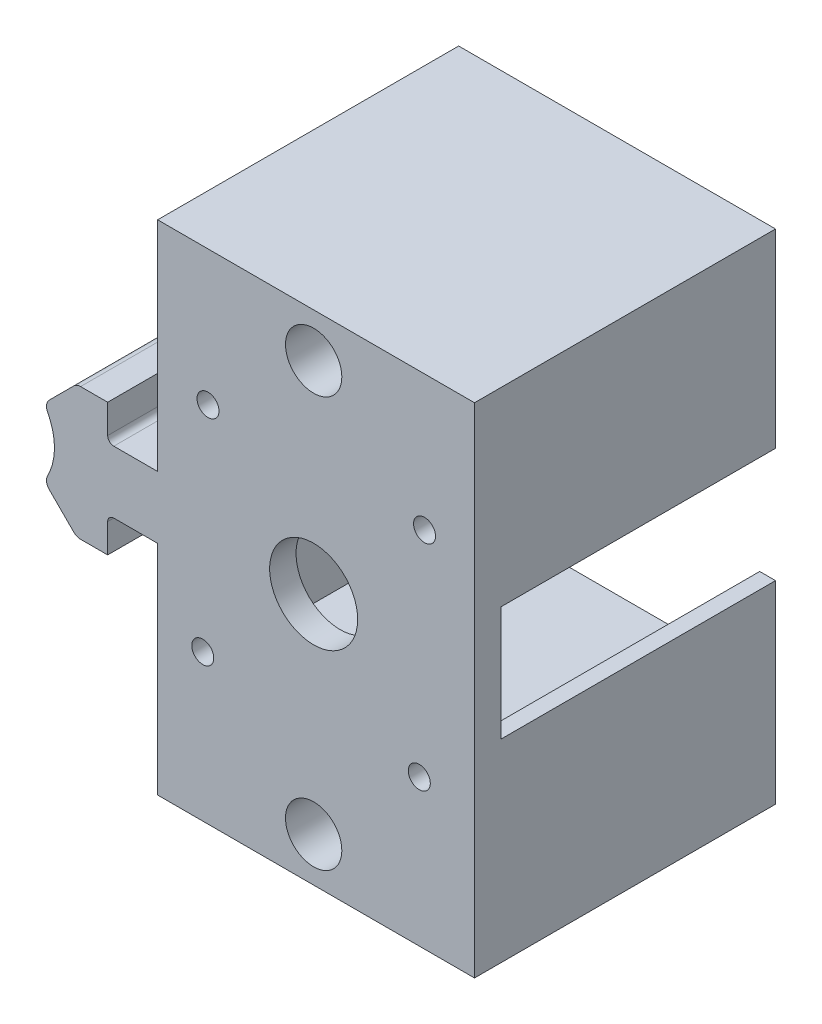
from build123d import *

# Parameters (mm, degrees)
BOSS_EXTRUDE1_DEPTH = 43.434
SKETCH3_W           = 3.81
SKETCH3_H           = 46.482
BOSS_EXTRUDE2_DEPTH = 43.688
BOSS_EXTRUDE5_DEPTH = 39.624
SKETCH9_R           = 6.35
CUT_EXTRUDE1_DEPTH  = 44.434
SKETCH10_R          = 1.5875
CUT_EXTRUDE2_DEPTH  = 4.81
SKETCH12_W          = 45.72
SKETCH12_H          = 43.434
BOSS_EXTRUDE6_DEPTH = 12.7
SKETCH13_W          = 45.72
SKETCH13_H          = 43.434
BOSS_EXTRUDE7_DEPTH = 12.7
SKETCH14_R          = 4.064
CUT_EXTRUDE3_DEPTH  = 6.35


with BuildPart() as part:
    # Sketch2 → Boss-Extrude1 (new body)
    with BuildSketch(Plane.XY.offset(816.492372385)):
        with BuildLine():
            Line((35.750095932, 34.097582937), (35.750095932, 33.285263123))
            ThreePointArc((35.750095932, 33.285263123), (35.457981836, 31.445408446), (34.772439624, 29.71323416))
            ThreePointArc((34.772439624, 29.71323416), (34.62798184, 28.864383796), (35.01595222, 28.095687512))
            Line((35.01595222, 28.095687512), (38.55890274, 24.552736992))
            ThreePointArc((38.55890274, 24.552736992), (39.005633691, 24.254240914), (39.532588778, 24.14942303))
            Line((39.532588778, 24.14942303), (43.443796213, 24.14942303))
            Line((43.443796213, 24.14942303), (43.443796213, 28.31442303))
            ThreePointArc((43.443796213, 28.31442303), (43.703006711, 28.940212531), (44.328796213, 29.19942303))
            Line((44.328796213, 29.19942303), (48.113296213, 29.19942303))
            Line((48.113296213, 29.19942303), (50.653296213, 29.19942303))
            Line((50.653296213, 29.19942303), (50.653296213, 10.45042303))
            Line((50.653296213, 10.45042303), (52.685296213, 10.45042303))
            Line((52.685296213, 10.45042303), (52.685296213, 56.93242303))
            Line((52.685296213, 56.93242303), (50.653296213, 56.93242303))
            Line((50.653296213, 56.93242303), (50.653296213, 38.18342303))
            Line((50.653296213, 38.18342303), (48.113296213, 38.18342303))
            Line((48.113296213, 38.18342303), (44.328796213, 38.18342303))
            ThreePointArc((44.328796213, 38.18342303), (43.703006711, 38.442633529), (43.443796213, 39.06842303))
            Line((43.443796213, 39.06842303), (43.443796213, 43.23342303))
            Line((43.443796213, 43.23342303), (39.532588778, 43.23342303))
            ThreePointArc((39.532588778, 43.23342303), (39.005633691, 43.128605146), (38.55890274, 42.830109068))
            Line((38.55890274, 42.830109068), (35.01595222, 39.287158548))
            ThreePointArc((35.01595222, 39.287158548), (34.62798184, 38.518462264), (34.772439624, 37.6696119))
            ThreePointArc((34.772439624, 37.6696119), (35.457981836, 35.937437615), (35.750095932, 34.097582937))
        make_face()
    extrude(amount=BOSS_EXTRUDE1_DEPTH)

    # Sketch3 → Boss-Extrude2 (add)
    with BuildSketch(Plane(origin=(52.685296213, 0, 0), x_dir=(0, 0, -1), z_dir=(1, 0, 0))):
        with Locations((-858.021372385, 33.69142303)):
            Rectangle(SKETCH3_W, SKETCH3_H)
    extrude(amount=BOSS_EXTRUDE2_DEPTH)

    # Sketch8 → Boss-Extrude5 (add)
    with BuildSketch(Plane(origin=(0, 0, 856.116372385), x_dir=(-1, 0, 0), z_dir=(0, 0, -1))):
        Polygon((-96.373296213, 56.93242303), (-52.685296213, 56.93242303), (-52.685296213, 54.90042303), (-94.087296213, 54.90042303), (-94.087296213, 42.220354744), (-96.373296213, 42.220354744), (-96.373296213, 54.90042303), align=None)
        Polygon((-96.373296213, 10.45042303), (-52.685296213, 10.45042303), (-52.685296213, 12.48242303), (-94.087296213, 12.48242303), (-94.087296213, 25.69042303), (-96.373296213, 25.69042303), (-96.373296213, 12.48242303), align=None)
    extrude(amount=BOSS_EXTRUDE5_DEPTH)

    # Sketch9 → Cut-Extrude1 (cut, through all)
    with BuildSketch(Plane.XY.offset(859.926372385)):
        with Locations((73.163747061, 34.125316724)):
            Circle(SKETCH9_R)
    extrude(amount=-CUT_EXTRUDE1_DEPTH, mode=Mode.SUBTRACT)

    # Sketch10 → Cut-Extrude2 (cut, through all)
    with BuildSketch(Plane(origin=(0, 0, 856.116372385), x_dir=(-1, 0, 0), z_dir=(0, 0, -1))):
        with Locations((-89.163747266, 50.124873673)):
            Circle(SKETCH10_R)
        with Locations((-57.921747266, 50.14642303)):
            Circle(SKETCH10_R)
        with Locations((-57.163746856, 18.90442303)):
            Circle(SKETCH10_R)
        with Locations((-88.405746856, 18.882873673)):
            Circle(SKETCH10_R)
    extrude(amount=-CUT_EXTRUDE2_DEPTH, mode=Mode.SUBTRACT)

    # Sketch12 → Boss-Extrude6 (add)
    with BuildSketch(Plane(origin=(0, 56.93242303, 0), x_dir=(1, 0, 0), z_dir=(0, 1, 0))):
        with Locations((73.513296213, -838.209372385)):
            Rectangle(SKETCH12_W, SKETCH12_H)
    extrude(amount=BOSS_EXTRUDE6_DEPTH)

    # Sketch13 → Boss-Extrude7 (add)
    with BuildSketch(Plane.XZ.offset(-10.45042303)):
        with Locations((73.513296213, 838.209372385)):
            Rectangle(SKETCH13_W, SKETCH13_H)
    extrude(amount=BOSS_EXTRUDE7_DEPTH)

    # Sketch14 → Cut-Extrude3 (cut)
    with BuildSketch(Plane.XY.offset(859.926372385)):
        with Locations((73.163747061, 63.28242303)):
            Circle(SKETCH14_R)
        with Locations((73.163747061, 4.10042303)):
            Circle(SKETCH14_R)
    extrude(amount=-CUT_EXTRUDE3_DEPTH, mode=Mode.SUBTRACT)


solid = part.part
